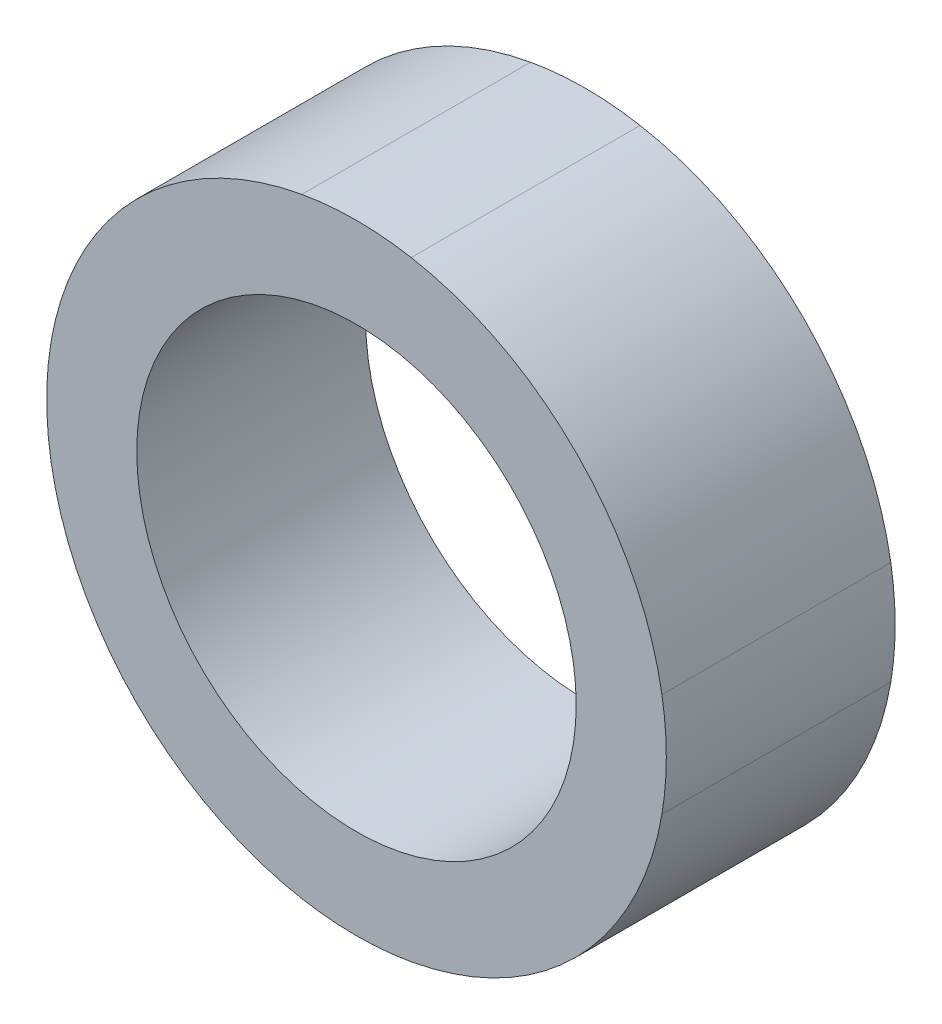
from build123d import *

# Parameters (mm, degrees)
SKETCH1_R           = 6.4643
SKETCH1_R_2         = 4.5847
BOSS_EXTRUDE1_DEPTH = 4.7752


with BuildPart() as part:
    # Sketch1 → Boss-Extrude1 (new body)
    with BuildSketch(Plane.XY):
        Circle(SKETCH1_R)
        Circle(SKETCH1_R_2, mode=Mode.SUBTRACT)
    extrude(amount=BOSS_EXTRUDE1_DEPTH)


solid = part.part
